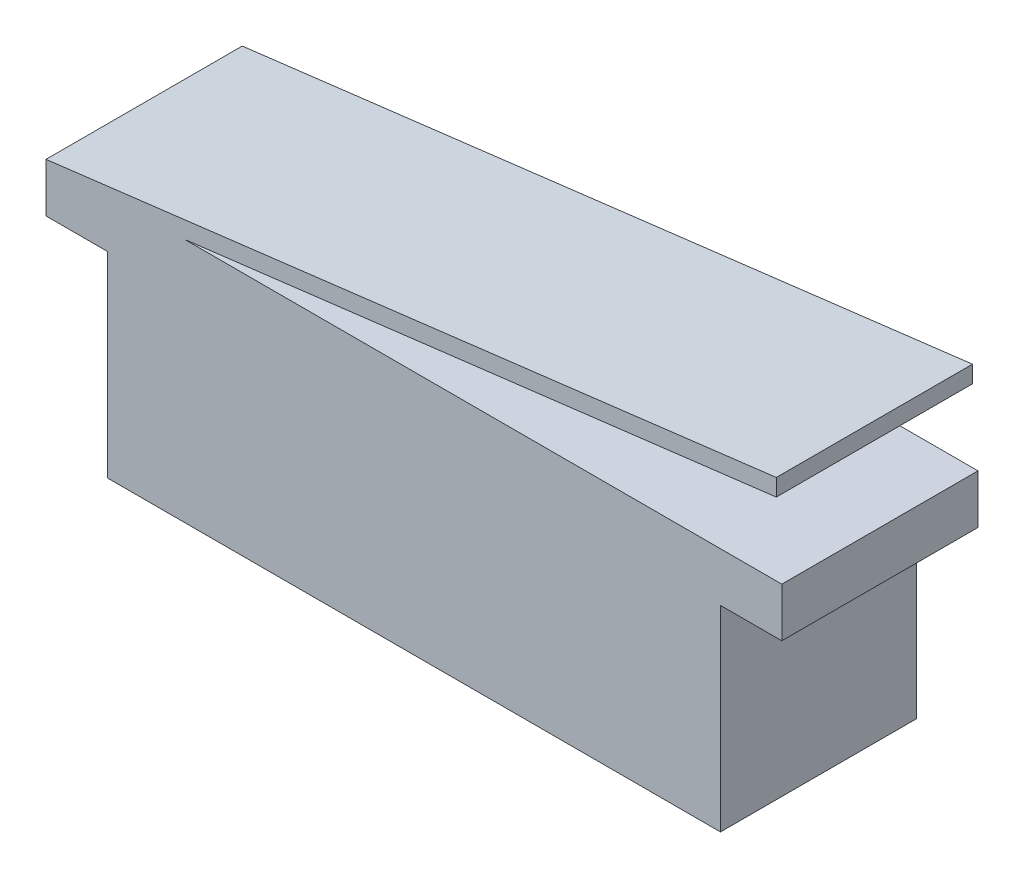
from build123d import *

# Parameters (mm, degrees)
SKETCH1_W           = 25
SKETCH1_H           = 8
BOSS_EXTRUDE1_DEPTH = 8


with BuildPart() as part:
    # Sketch1 → Boss-Extrude1 (new body)
    with BuildSketch(Plane.XY):
        Polygon((14.776384549, 9.656080302), (-15, 6), (-9.346191937, 6), (14.776384549, 8.961879962), align=None)
        Polygon((-9.346191937, 6), (-15, 6), (-15, 4), (-12.5, 4), (12.5, 4), (15, 4), (15, 6), align=None)
        Rectangle(SKETCH1_W, SKETCH1_H)
    extrude(amount=BOSS_EXTRUDE1_DEPTH)


solid = part.part
